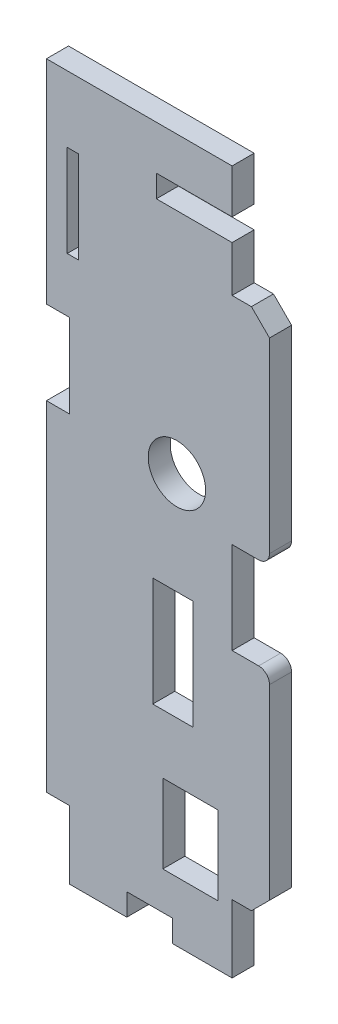
from build123d import *

# Parameters (mm, degrees)
MODEL_R             = 3.96545
MODEL_W             = 1.574799418
MODEL_H             = 12.699998915
MODEL_W_2           = 5.587999709
MODEL_H_2           = 15.087600797
MODEL_W_3           = 7.66
MODEL_H_3           = 10.87
BOSS_EXTRUDE1_DEPTH = 3.048


with BuildPart() as part:
    # Model → Boss-Extrude1 (new body)
    with BuildSketch(Plane.XY):
        with BuildLine():
            Line((25.653999648, 91.084402986), (15.189199708, 91.084402986))
            Line((15.189199708, 91.084402986), (15.189199708, 88.011001237))
            Line((15.189199708, 88.011001237), (25.653999648, 88.011001237))
            Line((25.653999648, 88.011001237), (25.653999648, 81.675999849))
            Line((25.653999648, 81.675999849), (28.323999648, 81.675999849))
            Line((28.323999648, 81.675999849), (30.823999648, 79.175999849))
            Line((30.823999648, 79.175999849), (30.823999648, 53.369499849))
            ThreePointArc((30.823999648, 53.369499849), (30.38465982, 52.308839677), (29.323999648, 51.869499849))
            Line((29.323999648, 51.869499849), (25.653999648, 51.869499849))
            Line((25.653999648, 51.869499849), (25.653999648, 39.189499849))
            Line((25.653999648, 39.189499849), (29.323999648, 39.189499849))
            ThreePointArc((29.323999648, 39.189499849), (30.38465982, 38.750160021), (30.823999648, 37.689499849))
            Line((30.823999648, 37.689499849), (30.823999648, 11.882999849))
            Line((30.823999648, 11.882999849), (28.323999648, 9.382999849))
            Line((28.323999648, 9.382999849), (25.653999648, 9.382999849))
            Line((25.653999648, 9.382999849), (25.653999648, 0))
            Line((25.653999648, 0), (17.399000004, 0))
            Line((17.399000004, 0), (17.399000004, 3.047999926))
            Line((17.399000004, 3.047999926), (11.099800467, 3.047999926))
            Line((11.099800467, 3.047999926), (11.099800467, 0))
            Line((11.099800467, 0), (3.174999729, 0))
            Line((3.174999729, 0), (3.174999729, 9.397999849))
            Line((3.174999729, 9.397999849), (0, 9.397999849))
            Line((0, 9.397999849), (0, 56.261000223))
            Line((0, 56.261000223), (3.174999729, 56.261000223))
            Line((3.174999729, 56.261000223), (3.174999729, 67.817998119))
            Line((3.174999729, 67.817998119), (0, 67.817998119))
            Line((0, 67.817998119), (0, 97.180393524))
            Line((0, 97.180393524), (25.653999648, 97.180393524))
            Line((25.653999648, 97.180393524), (25.653999648, 91.084402986))
        make_face()
        with Locations((18.027649688, 56.534049926)):
            Circle(MODEL_R, mode=Mode.SUBTRACT)
        with Locations((3.657599911, 81.661001779)):
            Rectangle(MODEL_W, MODEL_H, mode=Mode.SUBTRACT)
        with Locations((17.487899866, 34.848800861)):
            Rectangle(MODEL_W_2, MODEL_H_2, mode=Mode.SUBTRACT)
        with Locations((19.907249836, 13.696949929)):
            Rectangle(MODEL_W_3, MODEL_H_3, mode=Mode.SUBTRACT)
    extrude(amount=BOSS_EXTRUDE1_DEPTH)


solid = part.part
